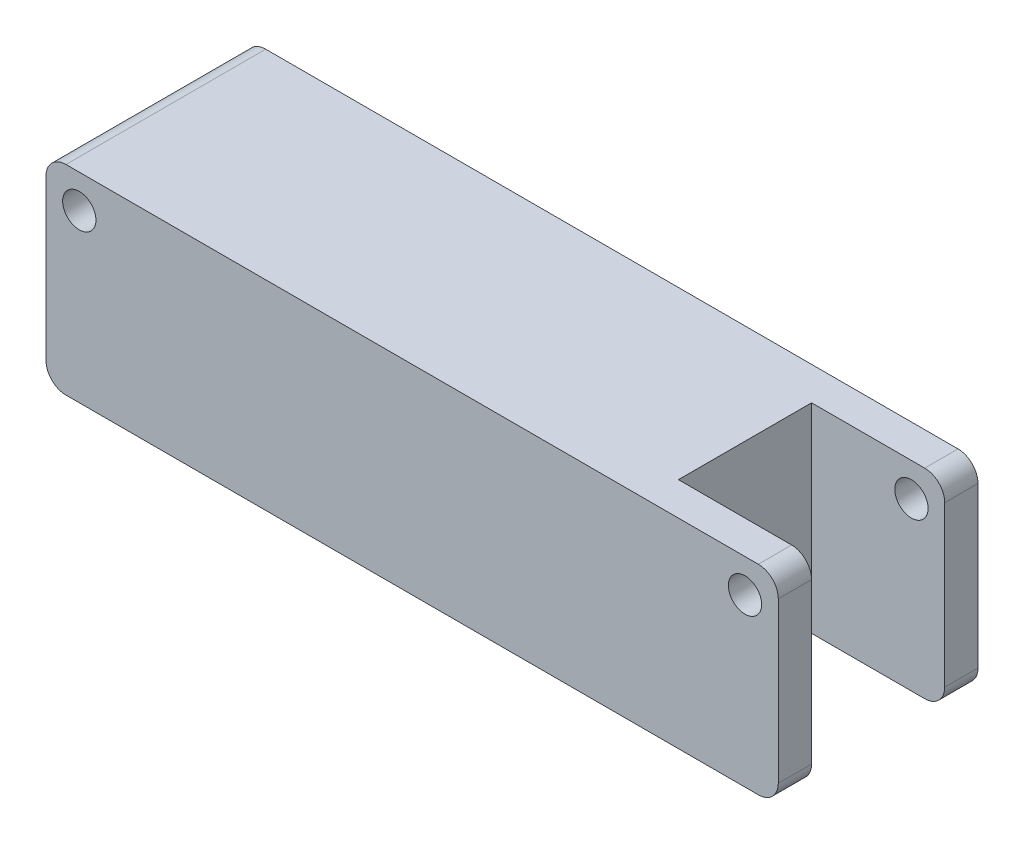
from build123d import *

# Parameters (mm, degrees)
ESQUISSE2_W             = 110
ESQUISSE2_H             = 30
BOSS_EXTRU_1_DEPTH      = 15
CONG_1_R                = 3
ESQUISSE4_W             = 20
ESQUISSE4_H             = 20
ENL_V_MAT_EXTRU_1_DEPTH = 116
ESQUISSE5_R             = 2.5
ENL_V_MAT_EXTRU_2_DEPTH = 116


with BuildPart() as part:
    # Esquisse2 → Boss.-Extru.1 (new, symmetric)
    with BuildSketch(Plane(origin=(0, 0, 0), x_dir=(1, 0, 0), z_dir=(0, 1, 0))):
        with Locations((55, 0)):
            Rectangle(ESQUISSE2_W, ESQUISSE2_H)
    extrude(amount=BOSS_EXTRU_1_DEPTH, both=True)

    # Congé1
    cong_1_edges = [part.edges().sort_by_distance(p)[0] for p in [
        (0, 15, 0),
        (110, 15, 0),
        (110, -15, 0),
        (0, -15, 0),
    ]]
    fillet(cong_1_edges, radius=CONG_1_R)

    # Esquisse4 → Enlèv. mat.-Extru.1 (cut, through all)
    with BuildSketch(Plane(origin=(0, 15, 0), x_dir=(1, 0, 0), z_dir=(0, 1, 0))):
        with Locations((100, 0)):
            Rectangle(ESQUISSE4_W, ESQUISSE4_H)
    extrude(amount=-ENL_V_MAT_EXTRU_1_DEPTH, mode=Mode.SUBTRACT)

    # Esquisse5 → Enlèv. mat.-Extru.2 (cut, through all)
    with BuildSketch(Plane(origin=(0, 0, -15), x_dir=(-1, 0, 0), z_dir=(0, 0, -1))):
        with Locations((-105, 10)):
            Circle(ESQUISSE5_R)
        with Locations((-5, 10)):
            Circle(ESQUISSE5_R)
    extrude(amount=-ENL_V_MAT_EXTRU_2_DEPTH, mode=Mode.SUBTRACT)


solid = part.part
